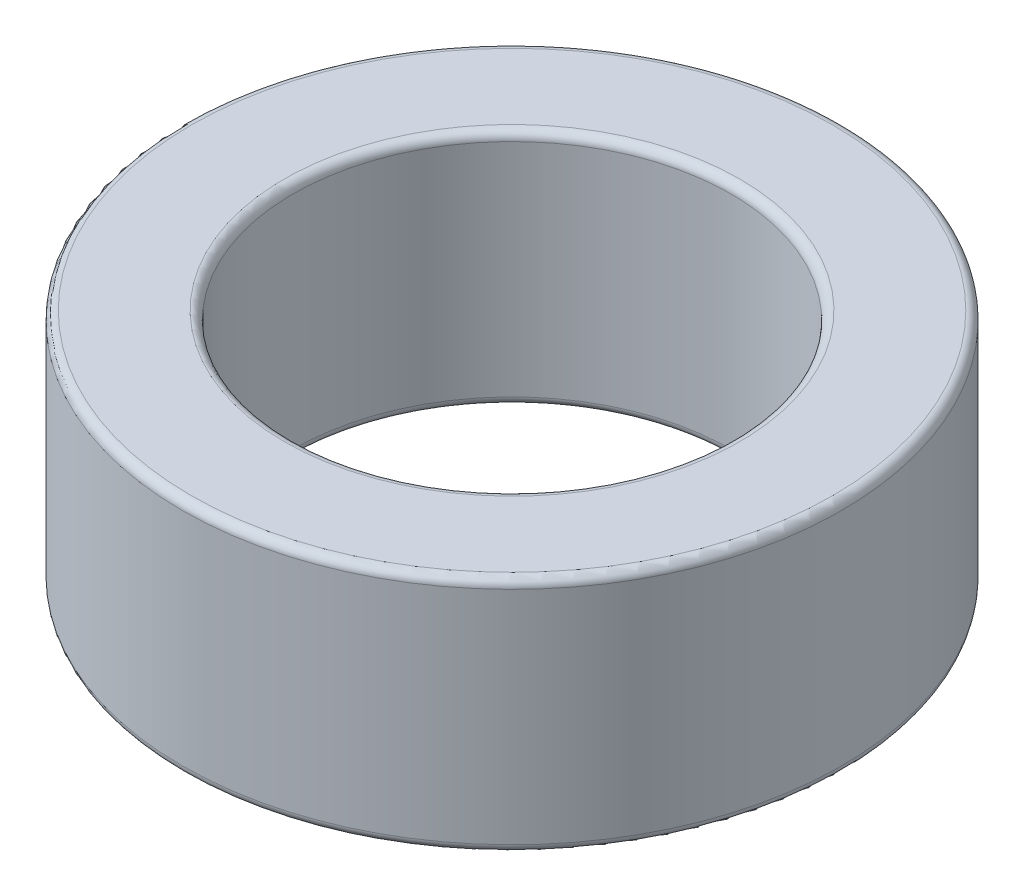
from build123d import *

# Parameters (mm, degrees)
SKETCH_1_R      = 3.8
SKETCH_1_R_2    = 2.525
EXTRUDE_1_DEPTH = 2.75
FILLET_1_R      = 0.1


with BuildPart() as part:
    # Эскиз1 → Бобышка-Вытянуть1 (new body)
    with BuildSketch(Plane(origin=(0, 0, 0), x_dir=(1, 0, 0), z_dir=(0, 1, 0))):
        Circle(SKETCH_1_R)
        Circle(SKETCH_1_R_2, mode=Mode.SUBTRACT)
    extrude(amount=EXTRUDE_1_DEPTH)

    # Скругление1
    fillet_1_edges = [part.edges().sort_by_distance(p)[0] for p in [
        (-3.8, 0, 0),
        (-3.8, 2.75, 0),
        (-2.525, 0, 0),
        (-2.525, 2.75, 0),
    ]]
    fillet(fillet_1_edges, radius=FILLET_1_R)


solid = part.part
